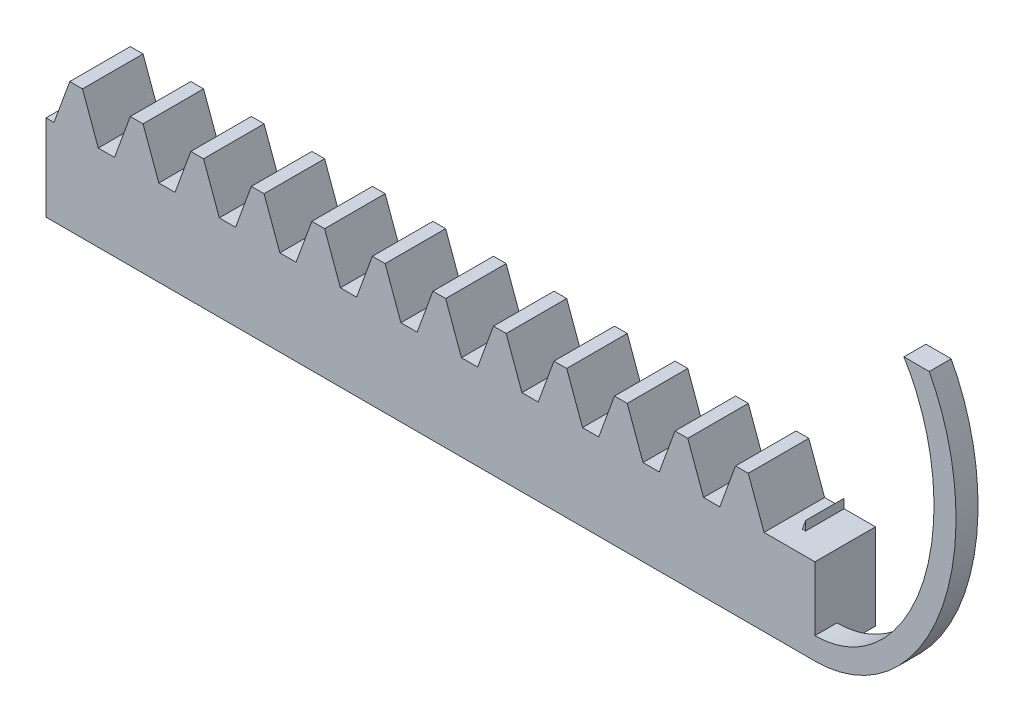
from build123d import *

# Parameters (mm, degrees)
BLANKSKE_W          = 100
BLANKSKE_H          = 11.75
BLANK_DEPTH         = 10
TOOTHCUTSIM_DEPTH   = 102.183311371
TEETHCUTS_COUNT     = 19
TEETHCUTS_PITCH     = 5.497787137
SKETCH_3_W          = 2.841503757
SKETCH_3_H          = 7.8125
EXTRUDE_1_DEPTH     = 10
EXTRUDE_2_DEPTH     = 2
SKETCH_6_W          = 102.841503757
SKETCH_6_H          = 15
CUT_EXTRUDE_2_DEPTH = 4.5
SKETCH_7_W          = 1.160244479
SKETCH_7_H          = 1.204796587
CUT_EXTRUDE_3_DEPTH = 2
SKETCH_8_W          = 16.666168626
SKETCH_8_H          = 26.64996686
CUT_EXTRUDE_5_DEPTH = 33
SKETCH_11_W         = 35.593118123
SKETCH_11_H         = 14.823069144
CUT_EXTRUDE_6_DEPTH = 2


with BuildPart() as part:
    # BlankSke → Blank (new body)
    with BuildSketch(Plane.XY):
        with Locations((50, 5.875)):
            Rectangle(BLANKSKE_W, BLANKSKE_H)
    extrude(amount=-BLANK_DEPTH)

    # TooCutSkeSim → ToothCutSim (cut, through all)
    with BuildSketch(Plane.XY):
        Polygon((0.737261897, 7.8125), (-0.737261897, 7.8125), (-2.179639538, 11.7754), (2.179639538, 11.7754), align=None)
    toothcutsim = extrude(amount=-TOOTHCUTSIM_DEPTH, mode=Mode.SUBTRACT)

    # TeethCuts: ToothCutSim ×19
    with Locations(*[(i * TEETHCUTS_PITCH, 0, 0) for i in range(1, TEETHCUTS_COUNT)]):
        add(toothcutsim, mode=Mode.SUBTRACT)

    # 草图3 → 凸台-拉伸1 (add)
    with BuildSketch(Plane.XY):
        with Locations((101.420751878, 3.90625)):
            Rectangle(SKETCH_3_W, SKETCH_3_H)
    extrude(amount=-EXTRUDE_1_DEPTH)

    # 草图5 → 凸台-拉伸2 (add)
    with BuildSketch(Plane.XY):
        with BuildLine():
            Line((102.841503757, 0), (102.841503757, 2))
            add(Edge.make_bspline(
                [(102.841503757, 2), (103.50529782, 2), (104.816875637, 2.17763142), (107.423271086, 3.255207974), (110.468253334, 6.015081397), (113.046627851, 11.280911472), (113.96899522, 17.633214309), (113.046627851, 23.985517146), (110.468253334, 29.251347221), (107.423271086, 32.011220644), (104.816875637, 33.088797198), (103.50529782, 33.266428618), (102.841503757, 33.266428618)],
                knots=[3.141592654, 3.141592654, 3.141592654, 3.141592654, 3.337942194, 3.534291735, 3.926990817, 4.319689899, 4.71238898, 5.105088062, 5.497787144, 5.890486225, 6.086835766, 6.283185307, 6.283185307, 6.283185307, 6.283185307], degree=3))
            Line((102.841503757, 33.266428618), (102.841503757, 35.266428618))
            add(Edge.make_bspline(
                [(102.841503757, 0), (115.66153943, 0), (115.66153943, 17.633214309), (115.66153943, 35.266428618), (102.841503757, 35.266428618)],
                knots=[3.141592654, 3.141592654, 3.141592654, 4.71238898, 4.71238898, 6.283185307, 6.283185307, 6.283185307], degree=2, weights=[1, 0.707106781, 1, 0.707106781, 1]))
        make_face()
    extrude(amount=-EXTRUDE_2_DEPTH)

    # 草图6 → 切除-拉伸2 (cut)
    with BuildSketch(Plane(origin=(0, 0, -10), x_dir=(-1, 0, 0), z_dir=(0, 0, -1))):
        with Locations((-51.420751879, 7.5)):
            Rectangle(SKETCH_6_W, SKETCH_6_H)
    extrude(amount=-CUT_EXTRUDE_2_DEPTH, mode=Mode.SUBTRACT)

    # 草图7 → 切除-拉伸3 (cut)
    with BuildSketch(Plane.XY):
        with Locations((99.931909363, 8.414898294)):
            Rectangle(SKETCH_7_W, SKETCH_7_H)
    extrude(amount=-CUT_EXTRUDE_3_DEPTH, mode=Mode.SUBTRACT)

    # 草图8 → 切除-拉伸5 (cut)
    with BuildSketch(Plane.ZY):
        Rectangle(SKETCH_8_W, SKETCH_8_H)
    extrude(amount=-CUT_EXTRUDE_5_DEPTH, mode=Mode.SUBTRACT)

    # 草图11 → 切除-拉伸6 (cut)
    with BuildSketch(Plane.XY):
        with Locations((104.465105415, 35.385155424)):
            Rectangle(SKETCH_11_W, SKETCH_11_H)
    extrude(amount=-CUT_EXTRUDE_6_DEPTH, mode=Mode.SUBTRACT)


solid = part.part
